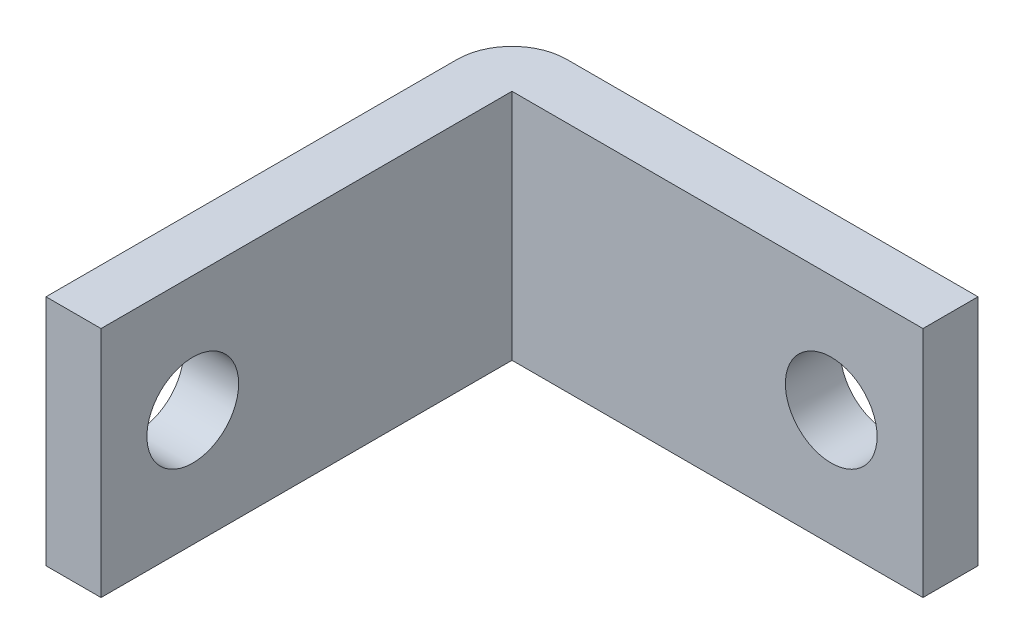
from build123d import *

# Parameters (mm, degrees)
CROQUIS1_W              = 25.4
CROQUIS1_H              = 12.7
SALIENTE_EXTRUIR1_DEPTH = 40
CROQUIS2_W              = 40.869814695
CROQUIS2_H              = 51.393723527
CORTAR_EXTRUIR1_DEPTH   = 30
CROQUIS3_R              = 2.5
CORTAR_EXTRUIR2_DEPTH   = 30
CROQUIS4_R              = 2.5
CORTAR_EXTRUIR3_DEPTH   = 30


with BuildPart() as part:
    # Croquis1 → Saliente-Extruir1 (new body)
    with BuildSketch(Plane.XY):
        with Locations((12.7, 6.35)):
            Rectangle(CROQUIS1_W, CROQUIS1_H)
    extrude(amount=SALIENTE_EXTRUIR1_DEPTH)

    # Croquis2 → Cortar-Extruir1 (cut)
    with BuildSketch(Plane(origin=(0, 12.7, 0), x_dir=(1, 0, 0), z_dir=(0, 1, 0))):
        with Locations((12.097003992, -18.212370052)):
            Rectangle(CROQUIS2_W, CROQUIS2_H)
        with BuildLine():
            Line((25.4, 0), (3, 0))
            ThreePointArc((3, 0), (0.878679656, -0.878679656), (0, -3))
            Line((0, -3), (0, -25.4))
            Line((0, -25.4), (3, -25.4))
            Line((3, -25.4), (3, -3))
            Line((3, -3), (25.4, -3))
            Line((25.4, -3), (25.4, 0))
        make_face(mode=Mode.SUBTRACT)
    extrude(amount=-CORTAR_EXTRUIR1_DEPTH, mode=Mode.SUBTRACT)

    # Croquis3 → Cortar-Extruir2 (cut)
    with BuildSketch(Plane(origin=(3, 0, 0), x_dir=(0, 0, -1), z_dir=(1, 0, 0))):
        with Locations((-20.4, 6.35)):
            Circle(CROQUIS3_R)
    extrude(amount=-CORTAR_EXTRUIR2_DEPTH, mode=Mode.SUBTRACT)

    # Croquis4 → Cortar-Extruir3 (cut)
    with BuildSketch(Plane.XY.offset(3)):
        with Locations((20.4, 6.35)):
            Circle(CROQUIS4_R)
    extrude(amount=-CORTAR_EXTRUIR3_DEPTH, mode=Mode.SUBTRACT)


solid = part.part
